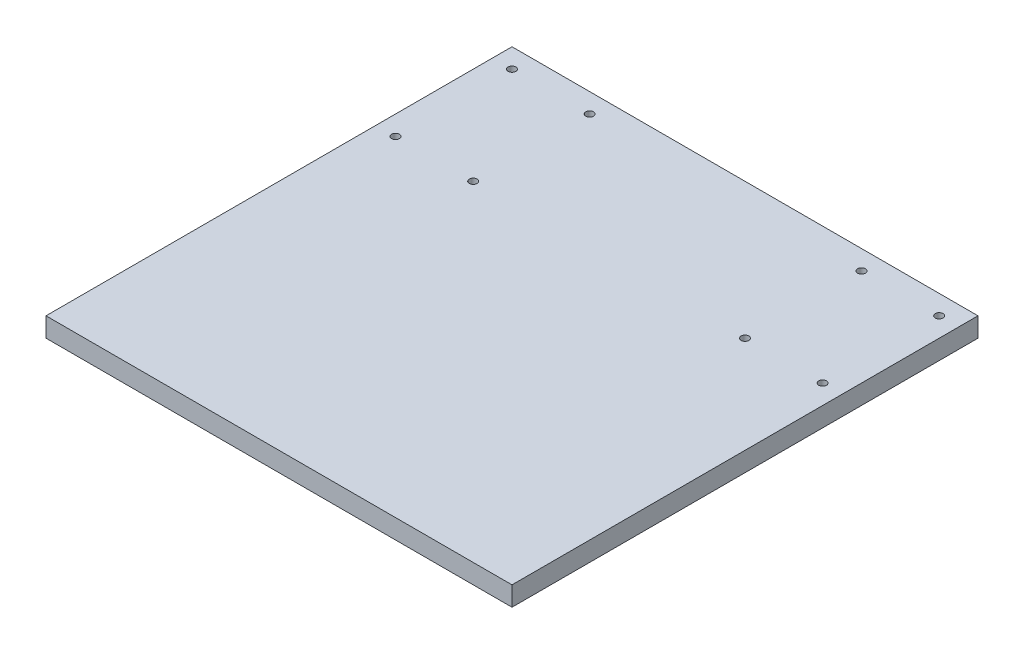
from build123d import *

# Parameters (mm, degrees)
ESBO_O2_W                = 240
ESBO_O2_H                = 240
ESBO_O2_R                = 2
RESSALTO_EXTRUS_O1_DEPTH = 10


with BuildPart() as part:
    # Esboço2 → Ressalto-extrusão1 (new body)
    with BuildSketch(Plane(origin=(0, 0, 0), x_dir=(1, 0, 0), z_dir=(0, 1, 0))):
        Rectangle(ESBO_O2_W, ESBO_O2_H)
        with Locations((-110, 110)):
            Circle(ESBO_O2_R, mode=Mode.SUBTRACT)
        with Locations((-110, 50)):
            Circle(ESBO_O2_R, mode=Mode.SUBTRACT)
        with Locations((-70, 110)):
            Circle(ESBO_O2_R, mode=Mode.SUBTRACT)
        with Locations((-70, 50)):
            Circle(ESBO_O2_R, mode=Mode.SUBTRACT)
        with Locations((70, 50)):
            Circle(ESBO_O2_R, mode=Mode.SUBTRACT)
        with Locations((70, 110)):
            Circle(ESBO_O2_R, mode=Mode.SUBTRACT)
        with Locations((110, 50)):
            Circle(ESBO_O2_R, mode=Mode.SUBTRACT)
        with Locations((110, 110)):
            Circle(ESBO_O2_R, mode=Mode.SUBTRACT)
    extrude(amount=RESSALTO_EXTRUS_O1_DEPTH)


solid = part.part
